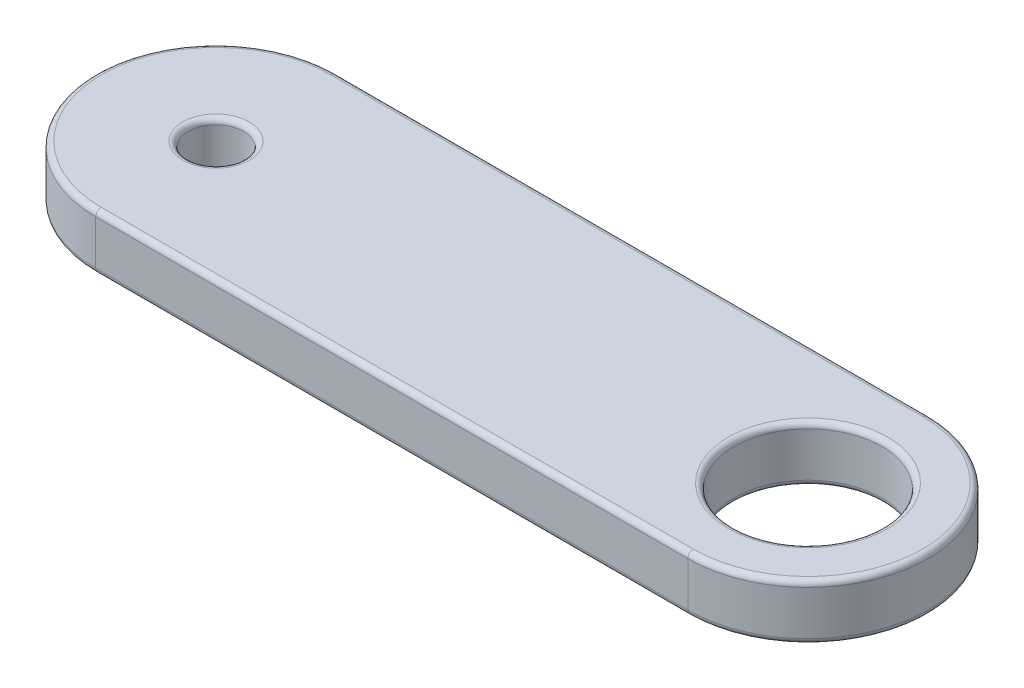
from build123d import *

# Parameters (mm, degrees)
SKETCH1_R           = 0.75
SKETCH1_R_2         = 2
BOSS_EXTRUDE1_DEPTH = 0.75
FILLET1_R           = 0.15


with BuildPart() as part:
    # Sketch1 → Boss-Extrude1 (new body, symmetric)
    with BuildSketch(Plane(origin=(0, 0, 0), x_dir=(1, 0, 0), z_dir=(0, 1, 0))):
        with BuildLine():
            Line((-8, 3.25), (8, 3.25))
            ThreePointArc((8, 3.25), (11.25, 0), (8, -3.25))
            Line((8, -3.25), (-8, -3.25))
            ThreePointArc((-8, -3.25), (-11.25, 0), (-8, 3.25))
        make_face()
        with Locations((-8, 0)):
            Circle(SKETCH1_R, mode=Mode.SUBTRACT)
        with Locations((8, 0)):
            Circle(SKETCH1_R_2, mode=Mode.SUBTRACT)
    extrude(amount=BOSS_EXTRUDE1_DEPTH, both=True)

    # Fillet1
    fillet1_edges = [part.edges().sort_by_distance(p)[0] for p in [
        (11.25, 0.75, 0),
        (-8.75, -0.75, 0),
        (-8.75, 0.75, 0),
        (0, 0.75, -3.25),
        (6, -0.75, 0),
        (6, 0.75, 0),
        (-11.25, 0.75, 0),
        (0, -0.75, -3.25),
        (11.25, -0.75, 0),
        (0, -0.75, 3.25),
        (-11.25, -0.75, 0),
        (0, 0.75, 3.25),
    ]]
    fillet(fillet1_edges, radius=FILLET1_R)


solid = part.part
